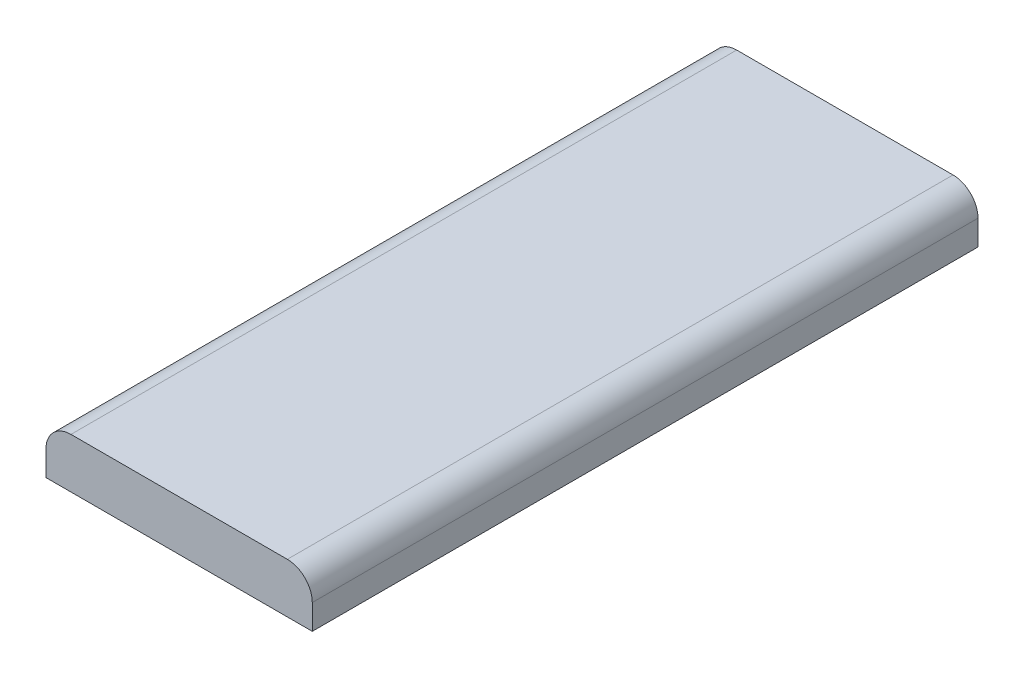
from build123d import *

# Parameters (mm, degrees)
SKETCH1_W           = 20
SKETCH1_H           = 50
BOSS_EXTRUDE1_DEPTH = 3.75
FILLET1_R           = 1.875


with BuildPart() as part:
    # Sketch1 → Boss-Extrude1 (new body)
    with BuildSketch(Plane(origin=(0, 0, 0), x_dir=(1, 0, 0), z_dir=(0, 1, 0))):
        Rectangle(SKETCH1_W, SKETCH1_H)
    extrude(amount=BOSS_EXTRUDE1_DEPTH)

    # Fillet1
    fillet1_edges = [part.edges().sort_by_distance(p)[0] for p in [
        (-10, 3.75, 0),
        (10, 3.75, 0),
    ]]
    fillet(fillet1_edges, radius=FILLET1_R)


solid = part.part
